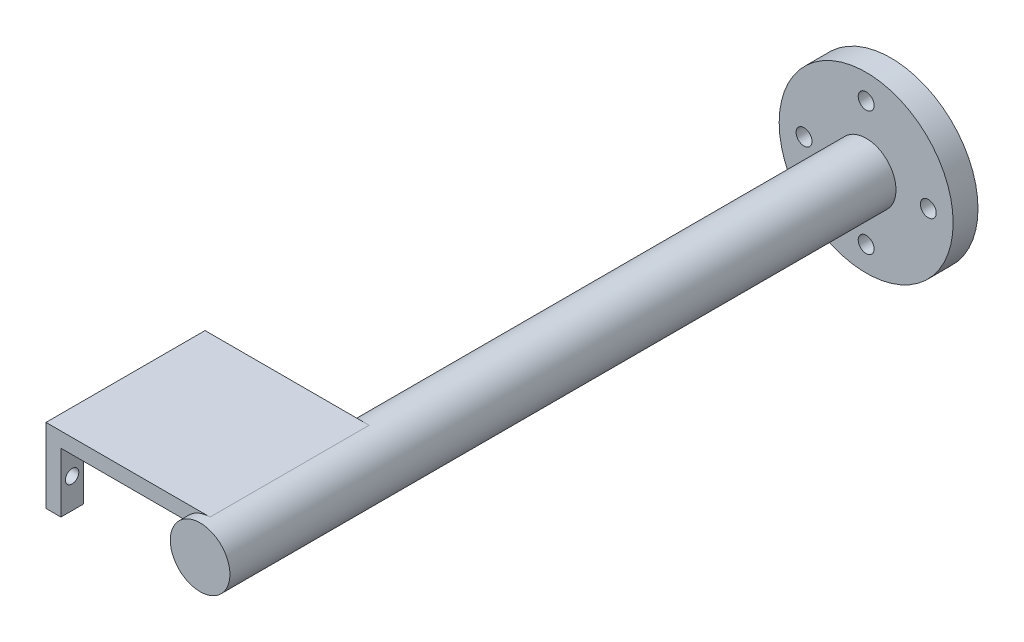
from build123d import *

# Parameters (mm, degrees)
SKETCH_1_R          = 4.1
EXTRUDE_1_DEPTH     = 32
SKETCH_3_R          = 1.35
SKETCH_3_W          = 23
SKETCH_3_H          = 12
CUT_EXTRUDE_1_DEPTH = 5
SKETCH_5_R          = 6
EXTRUDE_2_DEPTH     = 2
SKETCH_6_R          = 6
EXTRUDE_3_DEPTH     = 100
SKETCH_7_R          = 17.5
EXTRUDE_4_DEPTH     = 5
SKETCH_9_R          = 1.6
CUT_EXTRUDE_3_DEPTH = 140


with BuildPart() as part:
    # 草图1 → 凸台-拉伸1 (new body)
    with BuildSketch(Plane.XY):
        with BuildLine():
            Line((-32.405771928, 8.673637409), (-5.405771928, 8.673637409))
            Line((-5.405771928, 8.673637409), (0.594228072, 8.673637409))
            ThreePointArc((0.594228072, 8.673637409), (3.594228072, -2.522515014), (-4.601924351, 5.673637409))
            Line((-4.601924351, 5.673637409), (-29.405771928, 5.673637409))
            Line((-29.405771928, 5.673637409), (-29.405771928, -6.326362591))
            Line((-29.405771928, -6.326362591), (-32.405771928, -6.326362591))
            Line((-32.405771928, -6.326362591), (-32.405771928, 5.673637409))
            Line((-32.405771928, 5.673637409), (-32.405771928, 8.673637409))
        make_face()
        with Locations((0.594228072, 2.673637409)):
            Circle(SKETCH_1_R, mode=Mode.SUBTRACT)
    extrude(amount=EXTRUDE_1_DEPTH)

    # 草图3 → 切除-拉伸1 (cut)
    with BuildSketch(Plane.ZY.offset(32.405771928)):
        with Locations((29.75, -0.326362591)):
            Circle(SKETCH_3_R)
        with Locations((2.25, -0.326362591)):
            Circle(SKETCH_3_R)
        with Locations((16, -0.326362591)):
            Rectangle(SKETCH_3_W, SKETCH_3_H)
    extrude(amount=-CUT_EXTRUDE_1_DEPTH, mode=Mode.SUBTRACT)

    # 草图5 → 凸台-拉伸2 (add)
    with BuildSketch(Plane.XY.offset(32)):
        with Locations((0.594228072, 2.673637409)):
            Circle(SKETCH_5_R)
    extrude(amount=EXTRUDE_2_DEPTH)

    # 草图6 → 凸台-拉伸3 (add)
    with BuildSketch(Plane(origin=(0, 0, 0), x_dir=(-1, 0, 0), z_dir=(0, 0, -1))):
        with Locations((-0.594228072, 2.673637409)):
            Circle(SKETCH_6_R)
    extrude(amount=EXTRUDE_3_DEPTH)

    # 草图7 → 凸台-拉伸4 (add)
    with BuildSketch(Plane(origin=(0, 0, -100), x_dir=(-1, 0, 0), z_dir=(0, 0, -1))):
        with Locations((-0.594228072, 2.673637409)):
            Circle(SKETCH_7_R)
    extrude(amount=EXTRUDE_4_DEPTH)

    # 草图9 → 切除-拉伸3 (cut, through all)
    with BuildSketch(Plane(origin=(0, 0, -105), x_dir=(-1, 0, 0), z_dir=(0, 0, -1))):
        with Locations((11.905771928, 2.673637409)):
            Circle(SKETCH_9_R)
        with Locations((-0.594228072, 15.173637409)):
            Circle(SKETCH_9_R)
        with Locations((-13.094228072, 2.673637409)):
            Circle(SKETCH_9_R)
        with Locations((-0.594228072, -9.826362591)):
            Circle(SKETCH_9_R)
    extrude(amount=-CUT_EXTRUDE_3_DEPTH, mode=Mode.SUBTRACT)


solid = part.part
